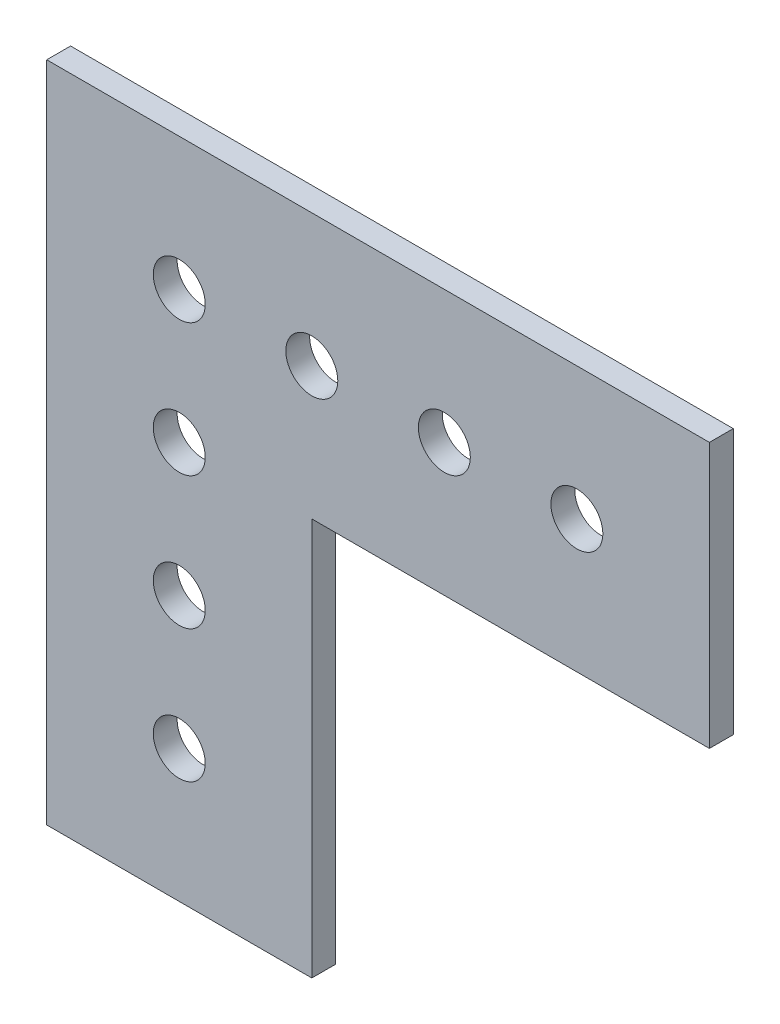
from build123d import *

# Parameters (mm, degrees)
SKETCH1_R           = 2.4892
BOSS_EXTRUDE1_DEPTH = 2.286


with BuildPart() as part:
    # Sketch1 → Boss-Extrude1 (new body)
    with BuildSketch(Plane(origin=(0, 0, 0), x_dir=(-1, 0, 0), z_dir=(0, 0, -1))):
        Polygon((12.7, 12.7), (-50.8, 12.7), (-50.8, -12.7), (-12.7, -12.7), (-12.7, -50.8), (12.7, -50.8), align=None)
        with Locations((0, -25.4)):
            Circle(SKETCH1_R, mode=Mode.SUBTRACT)
        with Locations((-38.1, 0)):
            Circle(SKETCH1_R, mode=Mode.SUBTRACT)
        with Locations((-12.7, 0)):
            Circle(SKETCH1_R, mode=Mode.SUBTRACT)
        Circle(SKETCH1_R, mode=Mode.SUBTRACT)
        with Locations((-25.4, 0)):
            Circle(SKETCH1_R, mode=Mode.SUBTRACT)
        with Locations((0, -12.7)):
            Circle(SKETCH1_R, mode=Mode.SUBTRACT)
        with Locations((0, -38.1)):
            Circle(SKETCH1_R, mode=Mode.SUBTRACT)
    extrude(amount=-BOSS_EXTRUDE1_DEPTH)


solid = part.part
